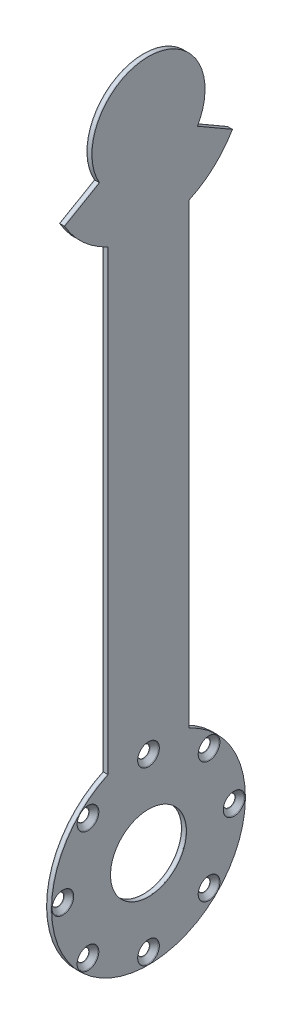
from build123d import *

# Parameters (mm, degrees)
BOSS_EXTRUDE1_DEPTH                          = 0.1
BOSS_EXTRUDE1_DEPTH_BACK                     = 0.25
SKETCH1_R                                    = 23.5
SKETCH2_R                                    = 23.5
BOSS_EXTRUDE2_DEPTH                          = 2.5
SKETCH4_R                                    = 23.5
BOSS_EXTRUDE3_DEPTH                          = 0.25
CSK_FOR_M6_HEX_SOCKET_COUNTERSUNK_CA_2_COUNT = 2
CSK_FOR_M6_HEX_SOCKET_COUNTERSUNK_CA_2_PITCH = 40.564443831
CSK_FOR_M6_HEX_SOCKET_COUNTERSUNK_CA_3_COUNT = 2
CSK_FOR_M6_HEX_SOCKET_COUNTERSUNK_CA_3_PITCH = 74.953318806
CSK_FOR_M6_HEX_SOCKET_COUNTERSUNK_CA_4_COUNT = 2
CSK_FOR_M6_HEX_SOCKET_COUNTERSUNK_CA_4_PITCH = 97.931230446
CSK_FOR_M6_HEX_SOCKET_COUNTERSUNK_CA_5_COUNT = 2
CSK_FOR_M6_HEX_SOCKET_COUNTERSUNK_CA_5_PITCH = 106
CSK_FOR_M6_HEX_SOCKET_COUNTERSUNK_CA_6_COUNT = 2
CSK_FOR_M6_HEX_SOCKET_COUNTERSUNK_CA_6_PITCH = 97.931230446
CSK_FOR_M6_HEX_SOCKET_COUNTERSUNK_CA_7_COUNT = 2
CSK_FOR_M6_HEX_SOCKET_COUNTERSUNK_CA_7_PITCH = 74.953318806
CSK_FOR_M6_HEX_SOCKET_COUNTERSUNK_CA_8_COUNT = 2
CSK_FOR_M6_HEX_SOCKET_COUNTERSUNK_CA_8_PITCH = 40.564443831


with BuildPart() as part:
    # Sketch1 → Boss-Extrude1 (new, two sides: drawn at the far end of the back side and taken through both)
    with BuildSketch(Plane(origin=(0, 0, 0), x_dir=(0, 0, -1), z_dir=(1, 0, 0)).offset(-BOSS_EXTRUDE1_DEPTH_BACK)):
        with BuildLine():
            Line((51.961524227, -30), (30.310889132, -17.5))
            ThreePointArc((30.310889132, -17.5), (0, 35), (-30.310889132, -17.5))
            Line((-30.310889132, -17.5), (-51.961524227, -30))
            ThreePointArc((-51.961524227, -30), (-40.390167668, -44.369295191), (-25, -54.543560573))
            Line((-25, -54.543560573), (-25, -337.456439427))
            ThreePointArc((-25, -337.456439427), (0, -452), (25, -337.456439427))
            Line((25, -337.456439427), (25, -54.543560573))
            ThreePointArc((25, -54.543560573), (40.390167668, -44.369295191), (51.961524227, -30))
        make_face()
        with Locations((0, -392)):
            Circle(SKETCH1_R, mode=Mode.SUBTRACT)
    extrude(amount=BOSS_EXTRUDE1_DEPTH + BOSS_EXTRUDE1_DEPTH_BACK)


with BuildPart() as body_2:
    # Sketch2 → Boss-Extrude2 (new body)
    with BuildSketch(Plane.ZY.offset(0.25)):
        with BuildLine():
            ThreePointArc((30.310889132, -17.5), (0, 35), (-30.310889132, -17.5))
            Line((-30.310889132, -17.5), (-51.961524227, -30))
            ThreePointArc((-51.961524227, -30), (-40.390167668, -44.369295191), (-25, -54.543560573))
            Line((-25, -54.543560573), (-25, -337.456439427))
            ThreePointArc((-25, -337.456439427), (0, -452), (25, -337.456439427))
            Line((25, -337.456439427), (25, -54.543560573))
            ThreePointArc((25, -54.543560573), (40.390167668, -44.369295191), (51.961524227, -30))
            Line((51.961524227, -30), (30.310889132, -17.5))
        make_face()
        with Locations((0, -392)):
            Circle(SKETCH2_R, mode=Mode.SUBTRACT)
    extrude(amount=BOSS_EXTRUDE2_DEPTH)


with BuildPart() as body_3:
    # Sketch4 → Boss-Extrude3 (new body)
    with BuildSketch(Plane.ZY.offset(2.75)):
        with BuildLine():
            Line((51.961524227, -30), (30.310889132, -17.5))
            ThreePointArc((30.310889132, -17.5), (0, 35), (-30.310889132, -17.5))
            Line((-30.310889132, -17.5), (-51.961524227, -30))
            ThreePointArc((-51.961524227, -30), (-40.390167668, -44.369295191), (-25, -54.543560573))
            Line((-25, -54.543560573), (-25, -337.456439427))
            ThreePointArc((-25, -337.456439427), (0, -452), (25, -337.456439427))
            Line((25, -337.456439427), (25, -54.543560573))
            ThreePointArc((25, -54.543560573), (40.390167668, -44.369295191), (51.961524227, -30))
        make_face()
        with Locations((0, -392)):
            Circle(SKETCH4_R, mode=Mode.SUBTRACT)
    extrude(amount=BOSS_EXTRUDE3_DEPTH)


with BuildPart() as csk_for_m6_hex_socket_countersunk_cap_sc_tool:
    # Sketch6 → CSK for M6 Hex Socket Countersunk Cap Sc (revolve)
    with BuildSketch(Plane(origin=(0.1, -354.523340597, -37.476659403), x_dir=(0, 0, -1), z_dir=(0, 1, 0))):
        Polygon((0, 0), (0, 3.1), (3.3, 3.1), (3.3, 3.42), (6.72, 0), align=None)
    csk_for_m6_hex_socket_countersunk_cap_sc = revolve(axis=Axis((6.45, -354.523340597, -37.476659403), (-1, 0, 0)))


with BuildPart() as part_1:
    add(part.part)

    # CSK for M6 Hex Socket Countersunk Cap Sc: cut by csk_for_m6_hex_socket_countersunk_cap_sc_tool
    add(csk_for_m6_hex_socket_countersunk_cap_sc_tool.part, mode=Mode.SUBTRACT)


with BuildPart() as body_2_1:
    add(body_2.part)

    # CSK for M6 Hex Socket Countersunk Cap Sc: cut by csk_for_m6_hex_socket_countersunk_cap_sc_tool
    add(csk_for_m6_hex_socket_countersunk_cap_sc_tool.part, mode=Mode.SUBTRACT)


with BuildPart() as body_3_1:
    add(body_3.part)

    # CSK for M6 Hex Socket Countersunk Cap Sc: cut by csk_for_m6_hex_socket_countersunk_cap_sc_tool
    add(csk_for_m6_hex_socket_countersunk_cap_sc_tool.part, mode=Mode.SUBTRACT)


with BuildPart() as csk_for_m6_hex_socket_countersunk_ca_2_tool:
    # CSK for M6 Hex Socket Countersunk Ca 2: CSK for M6 Hex Socket Countersunk Cap Sc ×2
    with Locations(*[Vector(0, -0.9238795325112888, -0.38268343236508495) * (i * CSK_FOR_M6_HEX_SOCKET_COUNTERSUNK_CA_2_PITCH) for i in range(1, CSK_FOR_M6_HEX_SOCKET_COUNTERSUNK_CA_2_COUNT)]):
        add(csk_for_m6_hex_socket_countersunk_cap_sc)


with BuildPart() as part_2:
    add(part_1.part)

    # CSK for M6 Hex Socket Countersunk Ca 2: cut by csk_for_m6_hex_socket_countersunk_ca_2_tool
    add(csk_for_m6_hex_socket_countersunk_ca_2_tool.part, mode=Mode.SUBTRACT)


with BuildPart() as body_2_2:
    add(body_2_1.part)

    # CSK for M6 Hex Socket Countersunk Ca 2: cut by csk_for_m6_hex_socket_countersunk_ca_2_tool
    add(csk_for_m6_hex_socket_countersunk_ca_2_tool.part, mode=Mode.SUBTRACT)


with BuildPart() as body_3_2:
    add(body_3_1.part)

    # CSK for M6 Hex Socket Countersunk Ca 2: cut by csk_for_m6_hex_socket_countersunk_ca_2_tool
    add(csk_for_m6_hex_socket_countersunk_ca_2_tool.part, mode=Mode.SUBTRACT)


with BuildPart() as csk_for_m6_hex_socket_countersunk_ca_3_tool:
    # CSK for M6 Hex Socket Countersunk Ca 3: CSK for M6 Hex Socket Countersunk Cap Sc ×2
    with Locations(*[(0, -i * CSK_FOR_M6_HEX_SOCKET_COUNTERSUNK_CA_3_PITCH, 0) for i in range(1, CSK_FOR_M6_HEX_SOCKET_COUNTERSUNK_CA_3_COUNT)]):
        add(csk_for_m6_hex_socket_countersunk_cap_sc)


with BuildPart() as part_3:
    add(part_2.part)

    # CSK for M6 Hex Socket Countersunk Ca 3: cut by csk_for_m6_hex_socket_countersunk_ca_3_tool
    add(csk_for_m6_hex_socket_countersunk_ca_3_tool.part, mode=Mode.SUBTRACT)


with BuildPart() as body_2_3:
    add(body_2_2.part)

    # CSK for M6 Hex Socket Countersunk Ca 3: cut by csk_for_m6_hex_socket_countersunk_ca_3_tool
    add(csk_for_m6_hex_socket_countersunk_ca_3_tool.part, mode=Mode.SUBTRACT)


with BuildPart() as body_3_3:
    add(body_3_2.part)

    # CSK for M6 Hex Socket Countersunk Ca 3: cut by csk_for_m6_hex_socket_countersunk_ca_3_tool
    add(csk_for_m6_hex_socket_countersunk_ca_3_tool.part, mode=Mode.SUBTRACT)


with BuildPart() as csk_for_m6_hex_socket_countersunk_ca_4_tool:
    # CSK for M6 Hex Socket Countersunk Ca 4: CSK for M6 Hex Socket Countersunk Cap Sc ×2
    with Locations(*[Vector(0, -0.9238795325112837, 0.38268343236509716) * (i * CSK_FOR_M6_HEX_SOCKET_COUNTERSUNK_CA_4_PITCH) for i in range(1, CSK_FOR_M6_HEX_SOCKET_COUNTERSUNK_CA_4_COUNT)]):
        add(csk_for_m6_hex_socket_countersunk_cap_sc)


with BuildPart() as part_4:
    add(part_3.part)

    # CSK for M6 Hex Socket Countersunk Ca 4: cut by csk_for_m6_hex_socket_countersunk_ca_4_tool
    add(csk_for_m6_hex_socket_countersunk_ca_4_tool.part, mode=Mode.SUBTRACT)


with BuildPart() as body_2_4:
    add(body_2_3.part)

    # CSK for M6 Hex Socket Countersunk Ca 4: cut by csk_for_m6_hex_socket_countersunk_ca_4_tool
    add(csk_for_m6_hex_socket_countersunk_ca_4_tool.part, mode=Mode.SUBTRACT)


with BuildPart() as body_3_4:
    add(body_3_3.part)

    # CSK for M6 Hex Socket Countersunk Ca 4: cut by csk_for_m6_hex_socket_countersunk_ca_4_tool
    add(csk_for_m6_hex_socket_countersunk_ca_4_tool.part, mode=Mode.SUBTRACT)


with BuildPart() as csk_for_m6_hex_socket_countersunk_ca_5_tool:
    # CSK for M6 Hex Socket Countersunk Ca 5: CSK for M6 Hex Socket Countersunk Cap Sc ×2
    with Locations(*[Vector(0, -0.7071067811865405, 0.7071067811865547) * (i * CSK_FOR_M6_HEX_SOCKET_COUNTERSUNK_CA_5_PITCH) for i in range(1, CSK_FOR_M6_HEX_SOCKET_COUNTERSUNK_CA_5_COUNT)]):
        add(csk_for_m6_hex_socket_countersunk_cap_sc)


with BuildPart() as part_5:
    add(part_4.part)

    # CSK for M6 Hex Socket Countersunk Ca 5: cut by csk_for_m6_hex_socket_countersunk_ca_5_tool
    add(csk_for_m6_hex_socket_countersunk_ca_5_tool.part, mode=Mode.SUBTRACT)


with BuildPart() as body_2_5:
    add(body_2_4.part)

    # CSK for M6 Hex Socket Countersunk Ca 5: cut by csk_for_m6_hex_socket_countersunk_ca_5_tool
    add(csk_for_m6_hex_socket_countersunk_ca_5_tool.part, mode=Mode.SUBTRACT)


with BuildPart() as body_3_5:
    add(body_3_4.part)

    # CSK for M6 Hex Socket Countersunk Ca 5: cut by csk_for_m6_hex_socket_countersunk_ca_5_tool
    add(csk_for_m6_hex_socket_countersunk_ca_5_tool.part, mode=Mode.SUBTRACT)


with BuildPart() as csk_for_m6_hex_socket_countersunk_ca_6_tool:
    # CSK for M6 Hex Socket Countersunk Ca 6: CSK for M6 Hex Socket Countersunk Cap Sc ×2
    with Locations(*[Vector(0, -0.3826834323650799, 0.9238795325112908) * (i * CSK_FOR_M6_HEX_SOCKET_COUNTERSUNK_CA_6_PITCH) for i in range(1, CSK_FOR_M6_HEX_SOCKET_COUNTERSUNK_CA_6_COUNT)]):
        add(csk_for_m6_hex_socket_countersunk_cap_sc)


with BuildPart() as part_6:
    add(part_5.part)

    # CSK for M6 Hex Socket Countersunk Ca 6: cut by csk_for_m6_hex_socket_countersunk_ca_6_tool
    add(csk_for_m6_hex_socket_countersunk_ca_6_tool.part, mode=Mode.SUBTRACT)


with BuildPart() as body_2_6:
    add(body_2_5.part)

    # CSK for M6 Hex Socket Countersunk Ca 6: cut by csk_for_m6_hex_socket_countersunk_ca_6_tool
    add(csk_for_m6_hex_socket_countersunk_ca_6_tool.part, mode=Mode.SUBTRACT)


with BuildPart() as body_3_6:
    add(body_3_5.part)

    # CSK for M6 Hex Socket Countersunk Ca 6: cut by csk_for_m6_hex_socket_countersunk_ca_6_tool
    add(csk_for_m6_hex_socket_countersunk_ca_6_tool.part, mode=Mode.SUBTRACT)


with BuildPart() as csk_for_m6_hex_socket_countersunk_ca_7_tool:
    # CSK for M6 Hex Socket Countersunk Ca 7: CSK for M6 Hex Socket Countersunk Cap Sc ×2
    with Locations(*[(0, 0, i * CSK_FOR_M6_HEX_SOCKET_COUNTERSUNK_CA_7_PITCH) for i in range(1, CSK_FOR_M6_HEX_SOCKET_COUNTERSUNK_CA_7_COUNT)]):
        add(csk_for_m6_hex_socket_countersunk_cap_sc)


with BuildPart() as part_7:
    add(part_6.part)

    # CSK for M6 Hex Socket Countersunk Ca 7: cut by csk_for_m6_hex_socket_countersunk_ca_7_tool
    add(csk_for_m6_hex_socket_countersunk_ca_7_tool.part, mode=Mode.SUBTRACT)


with BuildPart() as body_2_7:
    add(body_2_6.part)

    # CSK for M6 Hex Socket Countersunk Ca 7: cut by csk_for_m6_hex_socket_countersunk_ca_7_tool
    add(csk_for_m6_hex_socket_countersunk_ca_7_tool.part, mode=Mode.SUBTRACT)


with BuildPart() as body_3_7:
    add(body_3_6.part)

    # CSK for M6 Hex Socket Countersunk Ca 7: cut by csk_for_m6_hex_socket_countersunk_ca_7_tool
    add(csk_for_m6_hex_socket_countersunk_ca_7_tool.part, mode=Mode.SUBTRACT)


with BuildPart() as csk_for_m6_hex_socket_countersunk_ca_8_tool:
    # CSK for M6 Hex Socket Countersunk Ca 8: CSK for M6 Hex Socket Countersunk Cap Sc ×2
    with Locations(*[Vector(0, 0.38268343236510227, 0.9238795325112816) * (i * CSK_FOR_M6_HEX_SOCKET_COUNTERSUNK_CA_8_PITCH) for i in range(1, CSK_FOR_M6_HEX_SOCKET_COUNTERSUNK_CA_8_COUNT)]):
        add(csk_for_m6_hex_socket_countersunk_cap_sc)


with BuildPart() as part_8:
    add(part_7.part)

    # CSK for M6 Hex Socket Countersunk Ca 8: cut by csk_for_m6_hex_socket_countersunk_ca_8_tool
    add(csk_for_m6_hex_socket_countersunk_ca_8_tool.part, mode=Mode.SUBTRACT)


with BuildPart() as body_2_8:
    add(body_2_7.part)

    # CSK for M6 Hex Socket Countersunk Ca 8: cut by csk_for_m6_hex_socket_countersunk_ca_8_tool
    add(csk_for_m6_hex_socket_countersunk_ca_8_tool.part, mode=Mode.SUBTRACT)


with BuildPart() as body_3_8:
    add(body_3_7.part)

    # CSK for M6 Hex Socket Countersunk Ca 8: cut by csk_for_m6_hex_socket_countersunk_ca_8_tool
    add(csk_for_m6_hex_socket_countersunk_ca_8_tool.part, mode=Mode.SUBTRACT)


solid = Compound([part_8.part, body_2_8.part, body_3_8.part])
